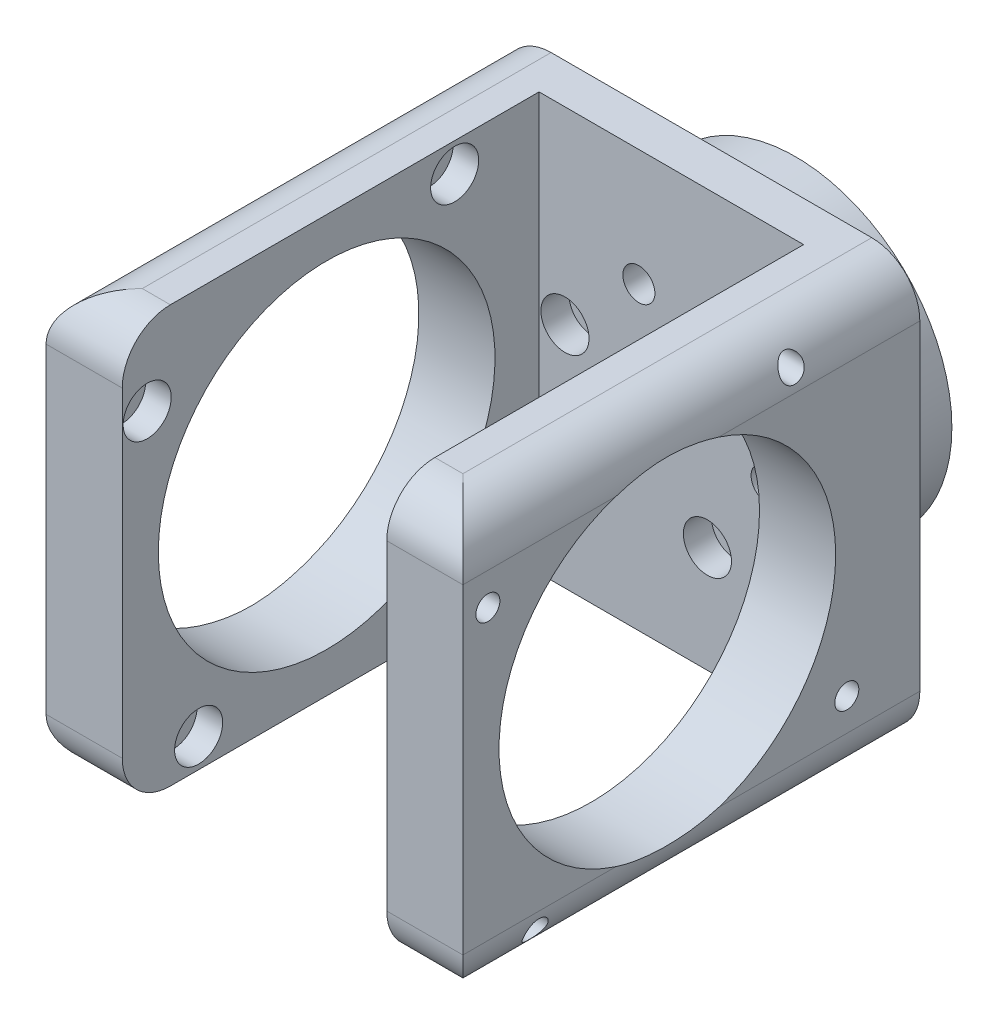
from build123d import *

# Parameters (mm, degrees)
SKETCH_1_R               = 2
SKETCH_1_R_2             = 1.25
EXTRUDE_1_DEPTH          = 10.5
SKETCH_2_R               = 1.25
SKETCH_2_R_2             = 2
EXTRUDE_2_DEPTH          = 5
SKETCH_3_R               = 3
CUT_EXTRUDE_1_DEPTH      = 3.5
CHAMFER_1_SIZE           = 2
EXTRUDE_3_DEPTH          = 52
CUT_EXTRUDE_2_DEPTH      = 1
CUT_EXTRUDE_2_DEPTH_BACK = 53
SKETCH_7_R               = 21
CUT_EXTRUDE_4_DEPTH      = 43.5
CUT_EXTRUDE_4_DEPTH_BACK = 10.5
SKETCH_8_R               = 1.5
CUT_EXTRUDE_5_DEPTH      = 43.5000001
CUT_EXTRUDE_5_DEPTH_BACK = 10.5000001
SKETCH_10_R              = 3
CUT_EXTRUDE_6_DEPTH      = 3.2
CUT_EXTRUDE_START        = 33
SKETCH_10_2_R            = 3
CUT_EXTRUDE_8_DEPTH      = 3.2


with BuildPart() as part:
    # 草图1 → 凸台-拉伸1 (new body)
    with BuildSketch(Plane.XY):
        with BuildLine():
            ThreePointArc((-6.500553872, 18.384580478), (-18.384580478, -6.500553872), (6.500553872, -18.384580478))
            ThreePointArc((6.500553872, -18.384580478), (18.384580478, 6.500553872), (-6.500553872, 18.384580478))
        make_face()
        with Locations((-4.050345105, 11.455007836)):
            Circle(SKETCH_1_R, mode=Mode.SUBTRACT)
        with Locations((8.772394705, 10.261339637)):
            Circle(SKETCH_1_R_2, mode=Mode.SUBTRACT)
        with Locations((11.945500339, -2.219802163)):
            Circle(SKETCH_1_R, mode=Mode.SUBTRACT)
        with Locations((4.50038345, -12.727786485)):
            Circle(SKETCH_1_R_2, mode=Mode.SUBTRACT)
        with Locations((-7.895155235, -9.235205673)):
            Circle(SKETCH_1_R, mode=Mode.SUBTRACT)
        with Locations((-13.272778155, 2.466446848)):
            Circle(SKETCH_1_R_2, mode=Mode.SUBTRACT)
    extrude(amount=EXTRUDE_1_DEPTH)

    # 草图2 → 凸台-拉伸2 (add)
    with BuildSketch(Plane.XY.offset(10.5)):
        with BuildLine():
            Line((20, -26), (-20, -26))
            ThreePointArc((-20, -26), (-24.242640687, -24.242640687), (-26, -20))
            Line((-26, -20), (-26, 20))
            ThreePointArc((-26, 20), (-24.242640687, 24.242640687), (-20, 26))
            Line((-20, 26), (20, 26))
            ThreePointArc((20, 26), (24.242640687, 24.242640687), (26, 20))
            Line((26, 20), (26, -20))
            ThreePointArc((26, -20), (24.242640687, -24.242640687), (20, -26))
        make_face()
        with Locations((4.50038345, -12.727786485)):
            Circle(SKETCH_2_R, mode=Mode.SUBTRACT)
        with Locations((-7.895155235, -9.235205673)):
            Circle(SKETCH_2_R_2, mode=Mode.SUBTRACT)
        with Locations((-13.272778155, 2.466446848)):
            Circle(SKETCH_2_R, mode=Mode.SUBTRACT)
        with Locations((-4.050345105, 11.455007836)):
            Circle(SKETCH_2_R_2, mode=Mode.SUBTRACT)
        with Locations((11.945500339, -2.219802163)):
            Circle(SKETCH_2_R_2, mode=Mode.SUBTRACT)
        with Locations((8.772394705, 10.261339637)):
            Circle(SKETCH_2_R, mode=Mode.SUBTRACT)
    extrude(amount=EXTRUDE_2_DEPTH)

    # 草图3 → 切除-拉伸1 (cut)
    with BuildSketch(Plane.XY.offset(15.5)):
        with Locations((4.50038345, -12.727786485)):
            Circle(SKETCH_3_R)
        with Locations((-13.272778155, 2.466446848)):
            Circle(SKETCH_3_R)
        with Locations((8.772394705, 10.261339637)):
            Circle(SKETCH_3_R)
    extrude(amount=-CUT_EXTRUDE_1_DEPTH, mode=Mode.SUBTRACT)

    # 倒角1
    chamfer_1_edges = [part.edges().sort_by_distance(p)[0] for p in [
        (6.500553872, -18.384580478, 10.5),
    ]]
    chamfer(chamfer_1_edges, length=CHAMFER_1_SIZE)

    # 草图4 → 凸台-拉伸3 (add)
    with BuildSketch(Plane.XY.offset(15.5)):
        with BuildLine():
            Line((-16.5, -26), (-20, -26))
            ThreePointArc((-20, -26), (-24.242640687, -24.242640687), (-26, -20))
            Line((-26, -20), (-26, 20))
            ThreePointArc((-26, 20), (-24.242640687, 24.242640687), (-20, 26))
            Line((-20, 26), (-16.5, 26))
            Line((-16.5, 26), (-16.5, -26))
        make_face()
        with BuildLine():
            Line((16.5, 26), (20, 26))
            ThreePointArc((20, 26), (24.242640687, 24.242640687), (26, 20))
            Line((26, 20), (26, -20))
            ThreePointArc((26, -20), (24.242640687, -24.242640687), (20, -26))
            Line((20, -26), (16.5, -26))
            Line((16.5, -26), (16.5, 26))
        make_face()
    extrude(amount=EXTRUDE_3_DEPTH)

    # 草图5 → 切除-拉伸2 (cut, two sides)
    with BuildSketch(Plane.ZY.offset(26)) as cut_extrude_2_sk:
        with BuildLine():
            Line((61.5, -26), (67.5, -26))
            Line((67.5, -26), (67.5, -20))
            ThreePointArc((67.5, -20), (65.742640687, -24.242640687), (61.5, -26))
        make_face()
        with BuildLine():
            Line((61.5, 26), (67.5, 26))
            Line((67.5, 26), (67.5, 20))
            ThreePointArc((67.5, 20), (65.742640687, 24.242640687), (61.5, 26))
        make_face()
    extrude(amount=CUT_EXTRUDE_2_DEPTH, mode=Mode.SUBTRACT)
    extrude(cut_extrude_2_sk.sketch, amount=-CUT_EXTRUDE_2_DEPTH_BACK, mode=Mode.SUBTRACT)

    # 草图7 → 切除-拉伸4 (cut, two sides)
    with BuildSketch(Plane(origin=(-16.5, 0, 0), x_dir=(0, 0, -1), z_dir=(1, 0, 0))) as cut_extrude_4_sk:
        with Locations((-42, 0)):
            Circle(SKETCH_7_R)
    extrude(amount=CUT_EXTRUDE_4_DEPTH, mode=Mode.SUBTRACT)
    extrude(cut_extrude_4_sk.sketch, amount=-CUT_EXTRUDE_4_DEPTH_BACK, mode=Mode.SUBTRACT)

    # 草图8 → 切除-拉伸5 (cut, two sides)
    with BuildSketch(Plane(origin=(-16.5, 0, 0), x_dir=(0, 0, -1), z_dir=(1, 0, 0))) as cut_extrude_5_sk:
        with Locations((-57.969331475, -22.388176617)):
            Circle(SKETCH_8_R)
        with Locations((-19.611823383, -15.969331475)):
            Circle(SKETCH_8_R)
        with Locations((-26.030668525, 22.388176617)):
            Circle(SKETCH_8_R)
        with Locations((-64.388176617, 15.969331475)):
            Circle(SKETCH_8_R)
    extrude(amount=CUT_EXTRUDE_5_DEPTH, mode=Mode.SUBTRACT)
    extrude(cut_extrude_5_sk.sketch, amount=-CUT_EXTRUDE_5_DEPTH_BACK, mode=Mode.SUBTRACT)

    # 草图10 → 切除-拉伸6 (cut)
    with BuildSketch(Plane(origin=(-16.5, 0, 0), x_dir=(0, 0, -1), z_dir=(1, 0, 0))):
        with Locations((-64.388176617, 15.969331475)):
            Circle(SKETCH_10_R)
        with Locations((-26.030668525, 22.388176617)):
            Circle(SKETCH_10_R)
        with Locations((-19.611823383, -15.969331475)):
            Circle(SKETCH_10_R)
        with Locations((-57.969331475, -22.388176617)):
            Circle(SKETCH_10_R)
    extrude(amount=-CUT_EXTRUDE_6_DEPTH, mode=Mode.SUBTRACT)

    # 草图10<2> → 切除-拉伸8 (cut)
    with BuildSketch(Plane(origin=(-16.5, 0, 0), x_dir=(0, 0, -1), z_dir=(1, 0, 0)).offset(CUT_EXTRUDE_START)):
        with Locations((-64.388176617, 15.969331475)):
            Circle(SKETCH_10_2_R)
        with Locations((-26.030668525, 22.388176617)):
            Circle(SKETCH_10_2_R)
        with Locations((-19.611823383, -15.969331475)):
            Circle(SKETCH_10_2_R)
        with Locations((-57.969331475, -22.388176617)):
            Circle(SKETCH_10_2_R)
    extrude(amount=CUT_EXTRUDE_8_DEPTH, mode=Mode.SUBTRACT)


solid = part.part
